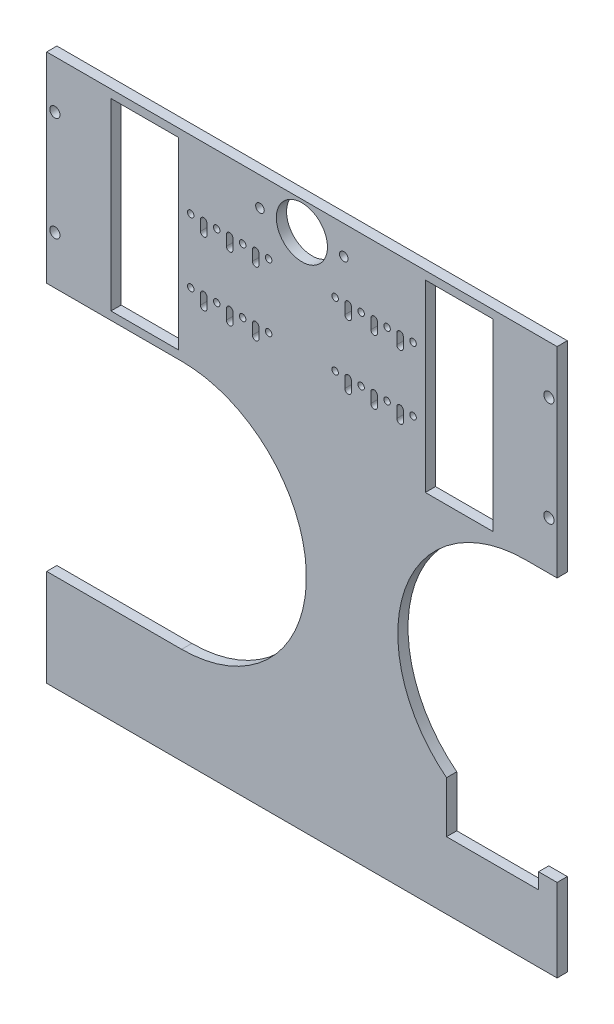
from build123d import *

# Parameters (mm, degrees)
SKETCH1_W           = 249.6
SKETCH1_H           = 350.4
SKETCH1_R           = 2.1
SKETCH1_R_2         = 2.5
SKETCH1_R_3         = 1.59
SKETCH1_R_4         = 12.5
SKETCH1_W_2         = 33
SKETCH1_H_2         = 90
BOSS_EXTRUDE1_DEPTH = 5
CUT_EXTRUDE1_DEPTH  = 6
SKETCH12_W          = 249.6
SKETCH12_H          = 5
CUT_EXTRUDE2_DEPTH  = 83


with BuildPart() as part:
    # Sketch1 → Boss-Extrude1 (new body)
    with BuildSketch(Plane.XY):
        with Locations((124.8, -175.2)):
            Rectangle(SKETCH1_W, SKETCH1_H)
        with Locations((104.3, -14)):
            Circle(SKETCH1_R, mode=Mode.SUBTRACT)
        with Locations((245.6, -23.5)):
            Circle(SKETCH1_R_2, mode=Mode.SUBTRACT)
        with Locations((245.6, -74.5)):
            Circle(SKETCH1_R_2, mode=Mode.SUBTRACT)
        with Locations((145.3, -14)):
            Circle(SKETCH1_R, mode=Mode.SUBTRACT)
        with Locations((179.16, -33.375)):
            Circle(SKETCH1_R_3, mode=Mode.SUBTRACT)
        with Locations((179.16, -64.625)):
            Circle(SKETCH1_R_3, mode=Mode.SUBTRACT)
        with Locations((124.8, -14)):
            Circle(SKETCH1_R_4, mode=Mode.SUBTRACT)
        with Locations((141.06, -33.375)):
            Circle(SKETCH1_R_3, mode=Mode.SUBTRACT)
        with Locations((153.76, -33.375)):
            Circle(SKETCH1_R_3, mode=Mode.SUBTRACT)
        with Locations((166.46, -33.375)):
            Circle(SKETCH1_R_3, mode=Mode.SUBTRACT)
        with Locations((141.06, -64.625)):
            Circle(SKETCH1_R_3, mode=Mode.SUBTRACT)
        with Locations((153.76, -64.625)):
            Circle(SKETCH1_R_3, mode=Mode.SUBTRACT)
        with Locations((166.46, -64.625)):
            Circle(SKETCH1_R_3, mode=Mode.SUBTRACT)
        with Locations((83.14, -64.625)):
            Circle(SKETCH1_R_3, mode=Mode.SUBTRACT)
        with Locations((95.84, -64.625)):
            Circle(SKETCH1_R_3, mode=Mode.SUBTRACT)
        with Locations((108.54, -64.625)):
            Circle(SKETCH1_R_3, mode=Mode.SUBTRACT)
        with Locations((83.14, -33.375)):
            Circle(SKETCH1_R_3, mode=Mode.SUBTRACT)
        with Locations((95.84, -33.375)):
            Circle(SKETCH1_R_3, mode=Mode.SUBTRACT)
        with Locations((108.54, -33.375)):
            Circle(SKETCH1_R_3, mode=Mode.SUBTRACT)
        with Locations((70.44, -64.625)):
            Circle(SKETCH1_R_3, mode=Mode.SUBTRACT)
        with Locations((70.44, -33.375)):
            Circle(SKETCH1_R_3, mode=Mode.SUBTRACT)
        with Locations((4, -74.5)):
            Circle(SKETCH1_R_2, mode=Mode.SUBTRACT)
        with Locations((4, -23.5)):
            Circle(SKETCH1_R_2, mode=Mode.SUBTRACT)
        with Locations((201.66, -49)):
            Rectangle(SKETCH1_W_2, SKETCH1_H_2, mode=Mode.SUBTRACT)
        with BuildLine():
            Line((145.8225, -33.375), (145.8225, -38.375))
            ThreePointArc((145.8225, -38.375), (147.41, -39.9625), (148.9975, -38.375))
            Line((148.9975, -38.375), (148.9975, -33.375))
            ThreePointArc((148.9975, -33.375), (147.41, -31.7875), (145.8225, -33.375))
        make_face(mode=Mode.SUBTRACT)
        with BuildLine():
            Line((158.52, -33.375), (158.52, -38.375))
            ThreePointArc((158.52, -38.375), (160.11, -39.965), (161.7, -38.375))
            Line((161.7, -38.375), (161.7, -33.375))
            ThreePointArc((161.7, -33.375), (160.11, -31.785), (158.52, -33.375))
        make_face(mode=Mode.SUBTRACT)
        with BuildLine():
            Line((171.22, -33.375), (171.22, -38.375))
            ThreePointArc((171.22, -38.375), (172.81, -39.965), (174.4, -38.375))
            Line((174.4, -38.375), (174.4, -33.375))
            ThreePointArc((174.4, -33.375), (172.81, -31.785), (171.22, -33.375))
        make_face(mode=Mode.SUBTRACT)
        with BuildLine():
            Line((145.8225, -64.625), (145.8225, -69.625))
            ThreePointArc((145.8225, -69.625), (147.41, -71.2125), (148.9975, -69.625))
            Line((148.9975, -69.625), (148.9975, -64.625))
            ThreePointArc((148.9975, -64.625), (147.41, -63.0375), (145.8225, -64.625))
        make_face(mode=Mode.SUBTRACT)
        with BuildLine():
            Line((158.52, -64.625), (158.52, -69.625))
            ThreePointArc((158.52, -69.625), (160.11, -71.215), (161.7, -69.625))
            Line((161.7, -69.625), (161.7, -64.625))
            ThreePointArc((161.7, -64.625), (160.11, -63.035), (158.52, -64.625))
        make_face(mode=Mode.SUBTRACT)
        with BuildLine():
            Line((171.22, -64.625), (171.22, -69.625))
            ThreePointArc((171.22, -69.625), (172.81, -71.215), (174.4, -69.625))
            Line((174.4, -69.625), (174.4, -64.625))
            ThreePointArc((174.4, -64.625), (172.81, -63.035), (171.22, -64.625))
        make_face(mode=Mode.SUBTRACT)
        with BuildLine():
            Line((103.7775, -33.375), (103.7775, -38.375))
            ThreePointArc((103.7775, -38.375), (102.19, -39.9625), (100.6025, -38.375))
            Line((100.6025, -38.375), (100.6025, -33.375))
            ThreePointArc((100.6025, -33.375), (102.19, -31.7875), (103.7775, -33.375))
        make_face(mode=Mode.SUBTRACT)
        with BuildLine():
            Line((91.08, -33.375), (91.08, -38.375))
            ThreePointArc((91.08, -38.375), (89.49, -39.965), (87.9, -38.375))
            Line((87.9, -38.375), (87.9, -33.375))
            ThreePointArc((87.9, -33.375), (89.49, -31.785), (91.08, -33.375))
        make_face(mode=Mode.SUBTRACT)
        with BuildLine():
            Line((78.38, -33.375), (78.38, -38.375))
            ThreePointArc((78.38, -38.375), (76.79, -39.965), (75.2, -38.375))
            Line((75.2, -38.375), (75.2, -33.375))
            ThreePointArc((75.2, -33.375), (76.79, -31.785), (78.38, -33.375))
        make_face(mode=Mode.SUBTRACT)
        with BuildLine():
            Line((103.7775, -64.625), (103.7775, -69.625))
            ThreePointArc((103.7775, -69.625), (102.19, -71.2125), (100.6025, -69.625))
            Line((100.6025, -69.625), (100.6025, -64.625))
            ThreePointArc((100.6025, -64.625), (102.19, -63.0375), (103.7775, -64.625))
        make_face(mode=Mode.SUBTRACT)
        with BuildLine():
            Line((91.08, -64.625), (91.08, -69.625))
            ThreePointArc((91.08, -69.625), (89.49, -71.215), (87.9, -69.625))
            Line((87.9, -69.625), (87.9, -64.625))
            ThreePointArc((87.9, -64.625), (89.49, -63.035), (91.08, -64.625))
        make_face(mode=Mode.SUBTRACT)
        with BuildLine():
            Line((78.38, -64.625), (78.38, -69.625))
            ThreePointArc((78.38, -69.625), (76.79, -71.215), (75.2, -69.625))
            Line((75.2, -69.625), (75.2, -64.625))
            ThreePointArc((75.2, -64.625), (76.79, -63.035), (78.38, -64.625))
        make_face(mode=Mode.SUBTRACT)
        with Locations((47.94, -49)):
            Rectangle(SKETCH1_W_2, SKETCH1_H_2, mode=Mode.SUBTRACT)
    extrude(amount=BOSS_EXTRUDE1_DEPTH)

    # Sketch11 → Cut-Extrude1 (cut, through all)
    with BuildSketch(Plane.XY.offset(5)):
        with BuildLine():
            Line((66, -220), (0, -220))
            Line((0, -220), (0, -98))
            Line((0, -98), (66, -98))
            ThreePointArc((66, -98), (127, -159), (66, -220))
        make_face()
        with BuildLine():
            Line((234.205987928, -98), (249.6, -98))
            Line((249.6, -98), (249.6, -226.927302483))
            Line((249.6, -226.927302483), (240.532540142, -226.927302483))
            Line((240.532540142, -226.927302483), (240.532540142, -234.598008477))
            Line((240.532540142, -234.598008477), (195.532540142, -234.598008477))
            Line((195.532540142, -234.598008477), (195.532540142, -209.598008477))
            ThreePointArc((195.532540142, -209.598008477), (175.151455799, -140.035097481), (234.205987928, -98))
        make_face()
    extrude(amount=-CUT_EXTRUDE1_DEPTH, mode=Mode.SUBTRACT)

    # Sketch12 → Cut-Extrude2 (cut)
    with BuildSketch(Plane.XZ.offset(350.4)):
        with Locations((124.8, 2.5)):
            Rectangle(SKETCH12_W, SKETCH12_H)
    extrude(amount=-CUT_EXTRUDE2_DEPTH, mode=Mode.SUBTRACT)


solid = part.part
